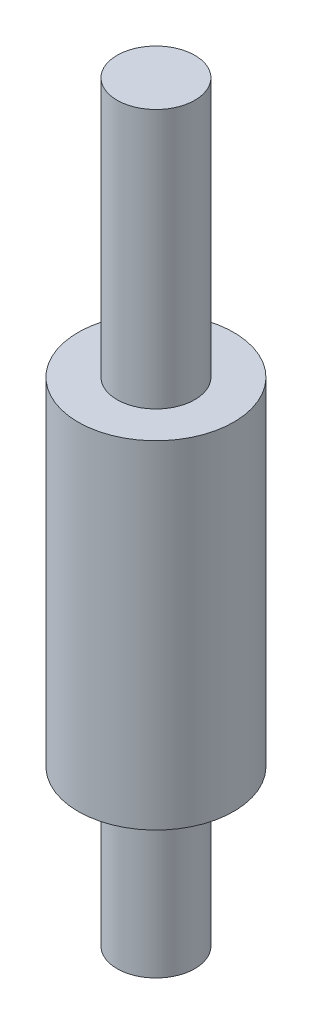
from build123d import *

# Parameters (mm, degrees)
SKETCH1_R           = 1.5
BOSS_EXTRUDE1_DEPTH = 6
SKETCH2_R           = 3
BOSS_EXTRUDE2_DEPTH = 13
SKETCH3_R           = 1.5
BOSS_EXTRUDE3_DEPTH = 10


with BuildPart() as part:
    # Sketch1 → Boss-Extrude1 (new body)
    with BuildSketch(Plane(origin=(0, 0, 0), x_dir=(1, 0, 0), z_dir=(0, 1, 0))):
        Circle(SKETCH1_R)
    extrude(amount=BOSS_EXTRUDE1_DEPTH)

    # Sketch2 → Boss-Extrude2 (add)
    with BuildSketch(Plane(origin=(0, 6, 0), x_dir=(1, 0, 0), z_dir=(0, 1, 0))):
        Circle(SKETCH2_R)
    extrude(amount=BOSS_EXTRUDE2_DEPTH)

    # Sketch3 → Boss-Extrude3 (add)
    with BuildSketch(Plane(origin=(0, 19, 0), x_dir=(1, 0, 0), z_dir=(0, 1, 0))):
        Circle(SKETCH3_R)
    extrude(amount=BOSS_EXTRUDE3_DEPTH)


solid = part.part
